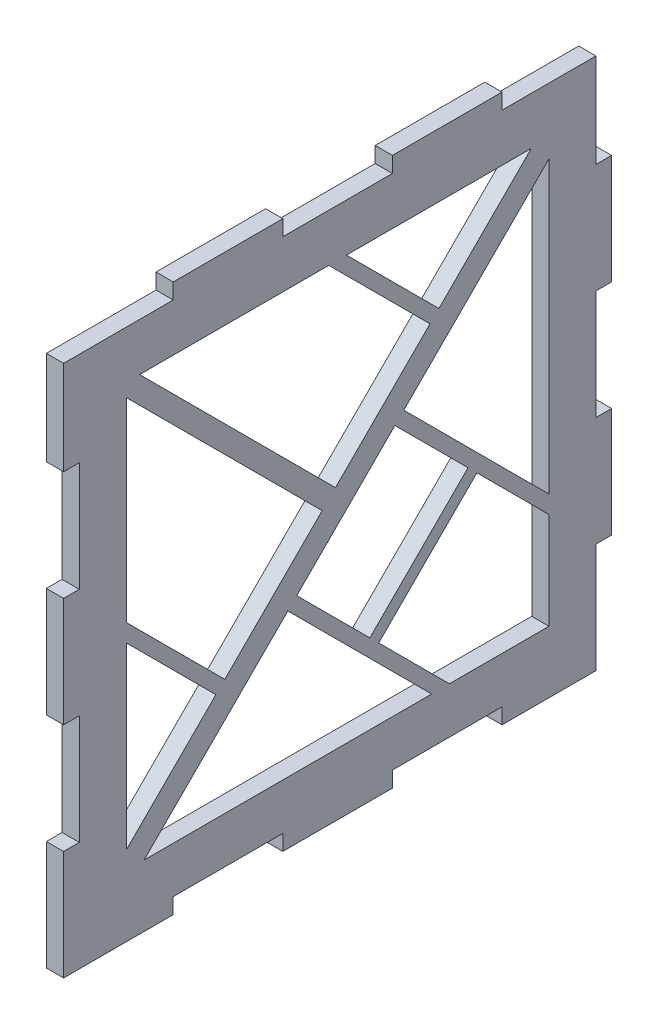
from build123d import *

# Parameters (mm, degrees)
EXTRUDE_5_DEPTH = 5.5


with BuildPart() as part:
    # Эскиз1 → Бобышка-Вытянуть5 (new body)
    with BuildSketch(Plane(origin=(0, 0, 0), x_dir=(0, 0, -1), z_dir=(1, 0, 0))):
        Polygon((0.00204272, 35), (0.00204272, 0.000377999), (35.00204272, 0.000377999), (35.00204272, 5.000377999), (70, 5.000377999), (70, 0.000377999), (105.00204272, 0.000377999), (105.00204272, 5.000377999), (140, 5.000377999), (140, 0.000377999), (170, 0.000377999), (170, 35.000377999), (175, 35.000377999), (175, 70), (170, 70), (170, 105.000377999), (175, 105.000377999), (175, 140), (170, 140), (170, 170.000377999), (140.00204272, 170.000377999), (140.00204272, 175.000377999), (139.90204272, 175.000377999), (105, 175.000377999), (105, 170.000377999), (70.00204272, 170.000377999), (70.00204272, 175.000377999), (35, 175.000377999), (35, 170.000377999), (0.00204272, 170.000377999), (0.00204272, 140.000377999), (5.00204272, 140.000377999), (5.00204272, 105), (0.00204272, 105), (0.00204272, 70.000377999), (5.00204272, 70.000377999), (5.00204272, 35), align=None)
        Polygon((71.614687911, 65.697512044), (117.541103017, 19.771096938), (25.688272806, 19.771096938), align=None, mode=Mode.SUBTRACT)
        Polygon((20.031418556, 82.648268821), (48.641577373, 54.038110004), (20.031418556, 25.427951188), align=None, mode=Mode.SUBTRACT)
        Polygon((100.61937762, 42.349676584), (131.978534805, 73.708833769), (155.00204272, 50.685325854), (155.00204272, 19.771096938), (123.197957266, 19.771096938), align=None, mode=Mode.SUBTRACT)
        Polygon((105.802272221, 99.885096353), (129.15010768, 76.537260894), (97.790950495, 45.178103709), (74.443115036, 68.525939168), align=None, mode=Mode.SUBTRACT)
        Polygon((20.031418556, 150.499080414), (82.56698317, 87.963515801), (51.470004498, 56.866537129), (20.031418556, 88.30512307), align=None, mode=Mode.SUBTRACT)
        Polygon((84.688303513, 154.741721101), (117.016745992, 122.413278623), (86.809623857, 92.206156488), (24.274059243, 154.741721101), align=None, mode=Mode.SUBTRACT)
        Polygon((108.630699345, 102.713523478), (155.00204272, 149.084866852), (155.00204272, 56.342180104), align=None, mode=Mode.SUBTRACT)
        Polygon((149.34518847, 154.741721101), (119.845173116, 125.241705748), (90.345157763, 154.741721101), align=None, mode=Mode.SUBTRACT)
    extrude(amount=EXTRUDE_5_DEPTH)


solid = part.part
